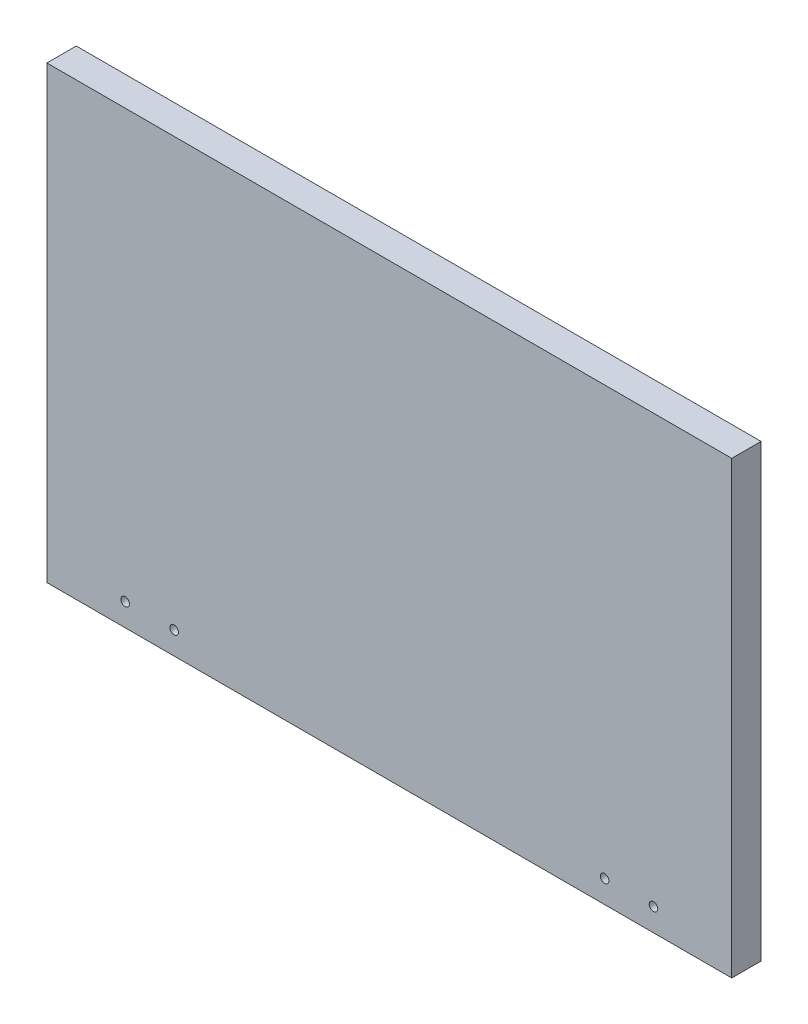
from build123d import *

# Parameters (mm, degrees)
SKETCH1_W           = 350
SKETCH1_H           = 230
BOSS_EXTRUDE1_DEPTH = 15
SKETCH2_R           = 2.2
CUT_EXTRUDE1_DEPTH  = 16


with BuildPart() as part:
    # Sketch1 → Boss-Extrude1 (new body)
    with BuildSketch(Plane.XY):
        Rectangle(SKETCH1_W, SKETCH1_H)
    extrude(amount=BOSS_EXTRUDE1_DEPTH)

    # Sketch2 → Cut-Extrude1 (cut, through all)
    with BuildSketch(Plane(origin=(0, 0, 0), x_dir=(-1, 0, 0), z_dir=(0, 0, -1))):
        with Locations((135, -103.4)):
            Circle(SKETCH2_R)
        with Locations((110, -103.4)):
            Circle(SKETCH2_R)
        with Locations((-135, -103.4)):
            Circle(SKETCH2_R)
        with Locations((-110, -103.4)):
            Circle(SKETCH2_R)
    extrude(amount=-CUT_EXTRUDE1_DEPTH, mode=Mode.SUBTRACT)


solid = part.part
